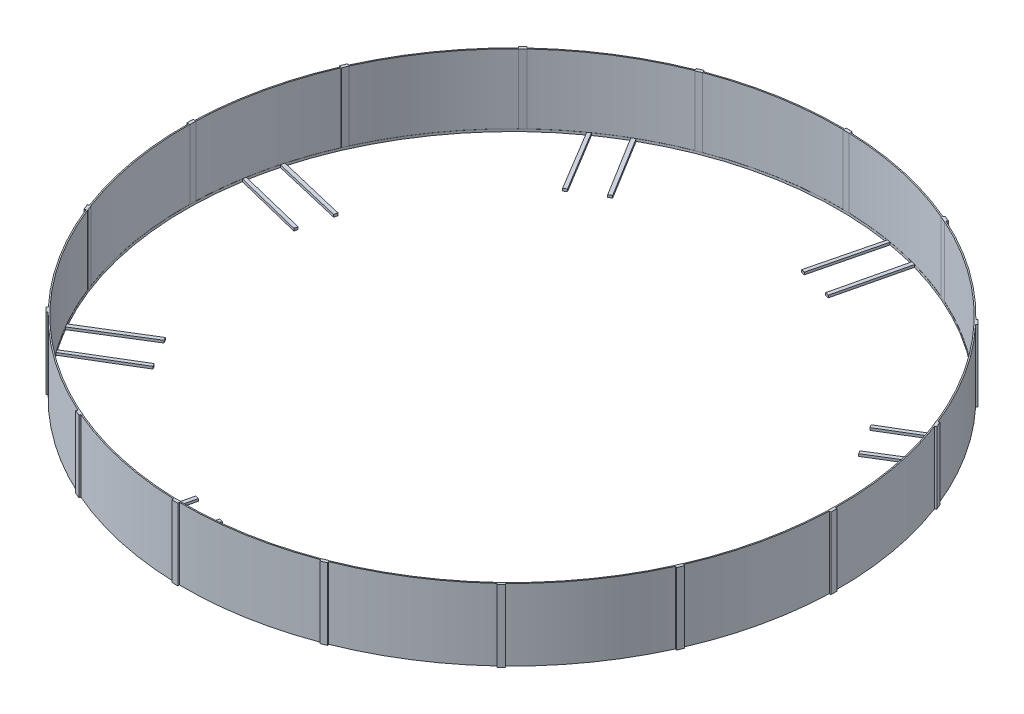
from build123d import *

# Parameters (mm, degrees)
SKETCH2_R           = 27500
BOSS_EXTRUDE1_DEPTH = 6000
SKETCH3_R           = 27400
CUT_EXTRUDE1_DEPTH  = 5800
SKETCH6_W           = 500
SKETCH6_H           = 6000
BOSS_EXTRUDE2_DEPTH = 125
CIRPATTERN1_COUNT   = 16
SKETCH8_R           = 27390
CUT_EXTRUDE2_DEPTH  = 6227
BOSS_EXTRUDE3_DEPTH = 200
CIRPATTERN2_COUNT   = 8
FILLET1_R           = 20
FILLET2_R           = 20


with BuildPart() as part:
    # Sketch2 → Boss-Extrude1 (new body)
    with BuildSketch(Plane(origin=(0, 0, 0), x_dir=(1, 0, 0), z_dir=(0, 1, 0))):
        Circle(SKETCH2_R)
    extrude(amount=BOSS_EXTRUDE1_DEPTH)

    # Sketch3 → Cut-Extrude1 (cut)
    with BuildSketch(Plane(origin=(0, 6000, 0), x_dir=(1, 0, 0), z_dir=(0, 1, 0))):
        Circle(SKETCH3_R)
    extrude(amount=-CUT_EXTRUDE1_DEPTH, mode=Mode.SUBTRACT)

    # Sketch6 → Boss-Extrude2 (add, symmetric)
    with BuildSketch(Plane(origin=(27500, 0, 0), x_dir=(0, 0, -1), z_dir=(1, 0, 0))):
        with Locations((-637.678148973, 3000)):
            Rectangle(SKETCH6_W, SKETCH6_H)
    boss_extrude2 = extrude(amount=BOSS_EXTRUDE2_DEPTH, both=True)

    # CirPattern1: Boss-Extrude2 ×16 about axis
    cirpattern1_axis = Axis((-0.099838763, 0, -0.002222088), (0, 1, 0))
    for i in range(1, CIRPATTERN1_COUNT):
        add(boss_extrude2.rotate(cirpattern1_axis, i * 360 / CIRPATTERN1_COUNT))

    # Sketch8 → Cut-Extrude2 (cut)
    with BuildSketch(Plane(origin=(0, 200, 0), x_dir=(1, 0, 0), z_dir=(0, 1, 0))):
        Circle(SKETCH8_R)
    extrude(amount=-CUT_EXTRUDE2_DEPTH, mode=Mode.SUBTRACT)

    # Sketch10 → Boss-Extrude3 (add)
    with BuildSketch(Plane(origin=(0, 0, 0), x_dir=(1, 0, 0), z_dir=(0, 1, 0))):
        Polygon((5674.449471115, 20624.936870229), (5965.678309656, 20552.924624036), (7360.975131404, 26388.39949512), (7045.930869189, 26466.087336938), align=None)
        Polygon((4448.034501077, 27106.711485076), (4723.505956769, 27038.782036925), (3290.003572919, 21212.547091039), (2998.73097018, 21284.382116574), align=None)
    boss_extrude3 = extrude(amount=BOSS_EXTRUDE3_DEPTH)

    # CirPattern2: Boss-Extrude3 ×8 about axis
    cirpattern2_axis = Axis((0, 0, 0), (0, 1, 0))
    for i in range(1, CIRPATTERN2_COUNT):
        add(boss_extrude3.rotate(cirpattern2_axis, i * 360 / CIRPATTERN2_COUNT))

    # Fillet1
    fillet1_edges = [part.edges().sort_by_distance(p)[0] for p in [
        (3144.36727155, 200, -21248.464603806),
    ]]
    fillet(fillet1_edges, radius=FILLET1_R)

    # Fillet2
    fillet2_edges = [part.edges().sort_by_distance(p)[0] for p in [
        (5820.063890386, 200, -20588.930747133),
    ]]
    fillet(fillet2_edges, radius=FILLET2_R)


solid = part.part
